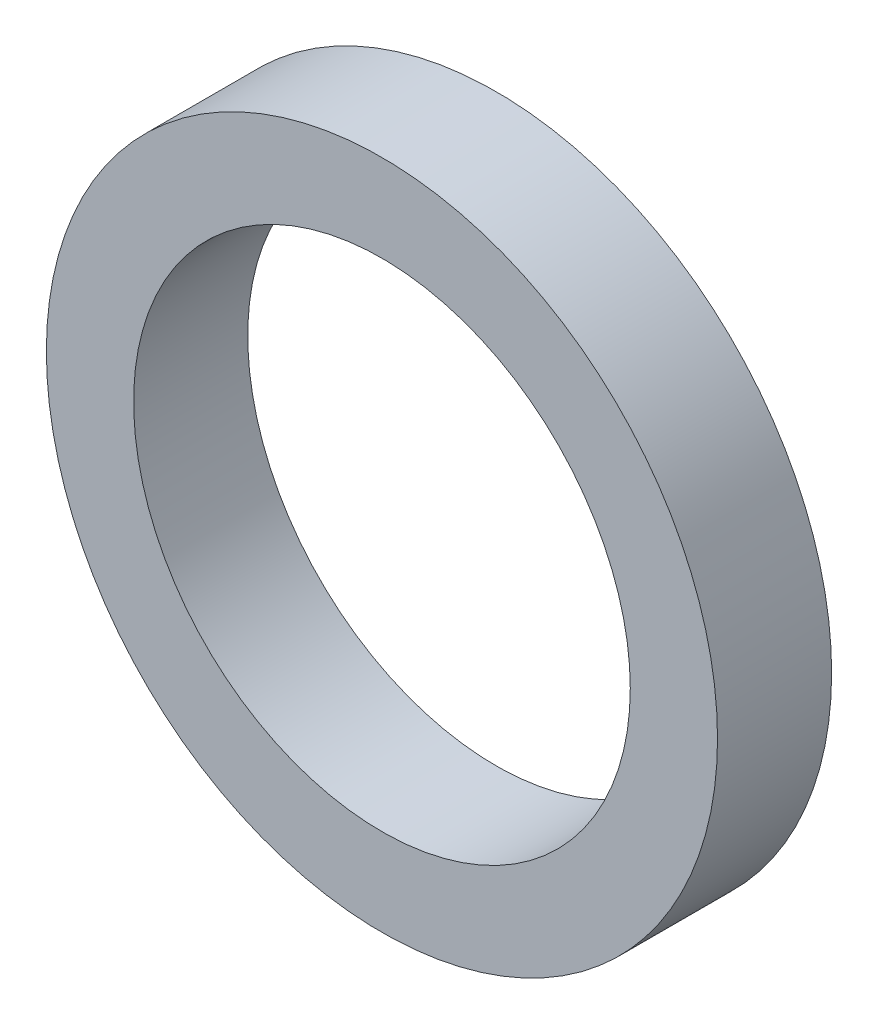
from build123d import *

# Parameters (mm, degrees)
SKETCH1_R           = 7.5
SKETCH1_R_2         = 5.55
BOSS_EXTRUDE1_DEPTH = 2.55


with BuildPart() as part:
    # Sketch1 → Boss-Extrude1 (new body)
    with BuildSketch(Plane.XY):
        Circle(SKETCH1_R)
        Circle(SKETCH1_R_2, mode=Mode.SUBTRACT)
    extrude(amount=BOSS_EXTRUDE1_DEPTH)


solid = part.part
